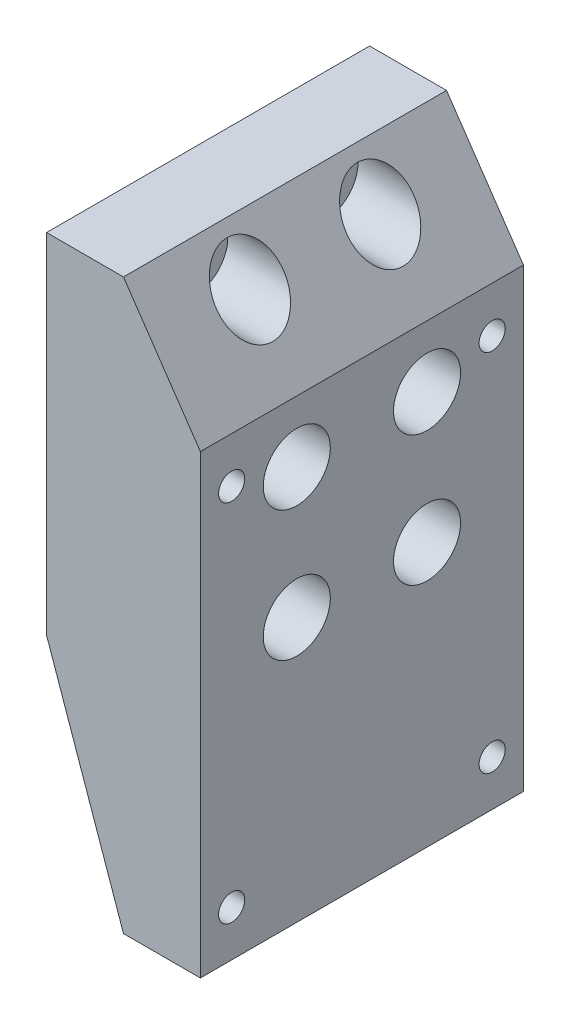
from build123d import *

# Parameters (mm, degrees)
BOSS_EXTRUDE1_DEPTH         = 63
SKETCH3_R                   = 3.5687
CUT_EXTRUDE1_DEPTH          = 63
SKETCH4_R                   = 6.5405
CUT_EXTRUDE2_DEPTH          = 20
F_1_4_20_TAPPED_HOLE1_D     = 5.1054
F_1_4_20_TAPPED_HOLE1_DEPTH = 10
F_1_4_20_TAPPED_HOLE1_TIP   = 1.533816902


with BuildPart() as part:
    # Sketch1 → Boss-Extrude1 (new body)
    with BuildSketch(Plane.XY):
        Polygon((-38.72257574, 45.396234333), (-38.72257574, -22.603765667), (-23.72257574, -65.503765667), (-8.72257574, -65.503765667), (-8.72257574, 23.396234333), (-23.72257574, 45.396234333), align=None)
    extrude(amount=BOSS_EXTRUDE1_DEPTH)

    # Sketch3 → Cut-Extrude1 (cut)
    with BuildSketch(Plane.ZY.offset(38.72257574)):
        with Locations((18.8, 36.796234333)):
            Circle(SKETCH3_R)
        with Locations((44.2, 36.796234333)):
            Circle(SKETCH3_R)
        with Locations((18.8, 11.396234333)):
            Circle(SKETCH3_R)
        with Locations((44.2, 11.396234333)):
            Circle(SKETCH3_R)
        with Locations((18.8, -14.003765667)):
            Circle(SKETCH3_R)
        with Locations((44.2, -14.003765667)):
            Circle(SKETCH3_R)
    extrude(amount=-CUT_EXTRUDE1_DEPTH, mode=Mode.SUBTRACT)

    # Sketch4 → Cut-Extrude2 (cut)
    with BuildSketch(Plane(origin=(-8.72257574, 0, 0), x_dir=(0, 0, -1), z_dir=(1, 0, 0))):
        with Locations((-44.2, -14.003765667)):
            Circle(SKETCH4_R)
        with Locations((-18.8, -14.003765667)):
            Circle(SKETCH4_R)
        with Locations((-18.8, 11.396234333)):
            Circle(SKETCH4_R)
        with Locations((-44.2, 36.796234333)):
            Circle(SKETCH4_R)
        with Locations((-18.8, 36.796234333)):
            Circle(SKETCH4_R)
        with Locations((-44.2, 11.396234333)):
            Circle(SKETCH4_R)
    extrude(amount=-CUT_EXTRUDE2_DEPTH, mode=Mode.SUBTRACT)

    # 1/4-20 Tapped Hole1
    with Locations(Plane(origin=(-8.72257574, 0, 0), x_dir=(0, 0, -1), z_dir=(1, 0, 0))):
        with Locations((-56.9, 14.506234333), (-6.1, 14.506234333), (-56.9, -56.613765667), (-6.1, -56.613765667)):
            Hole(F_1_4_20_TAPPED_HOLE1_D / 2, depth=F_1_4_20_TAPPED_HOLE1_DEPTH)
            with Locations((0, 0, -(F_1_4_20_TAPPED_HOLE1_DEPTH + F_1_4_20_TAPPED_HOLE1_TIP / 2))):  # 118° drill point
                Cone(0, F_1_4_20_TAPPED_HOLE1_D / 2, F_1_4_20_TAPPED_HOLE1_TIP, mode=Mode.SUBTRACT)


solid = part.part
